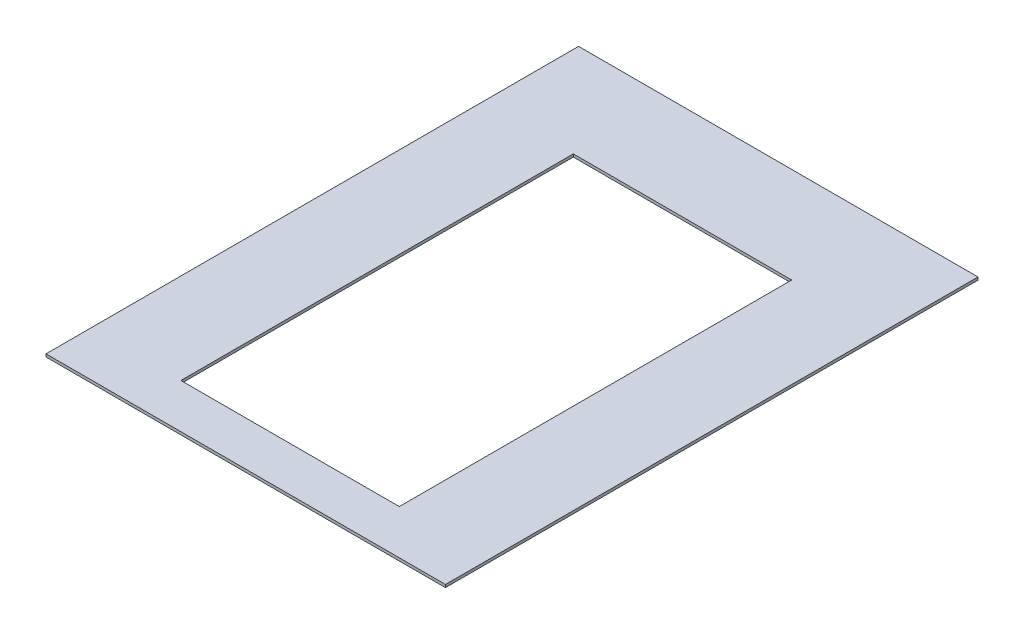
from build123d import *

# Parameters (mm, degrees)
SKETCH1_W           = 457.2
SKETCH1_H           = 609.6
SKETCH1_W_2         = 250
SKETCH1_H_2         = 449.2
BOSS_EXTRUDE1_DEPTH = 1.5875


with BuildPart() as part:
    # Sketch1 → Boss-Extrude1 (new body, symmetric)
    with BuildSketch(Plane(origin=(0, 0, 0), x_dir=(1, 0, 0), z_dir=(0, 1, 0))):
        Rectangle(SKETCH1_W, SKETCH1_H)
        with Locations((0, -29.4)):
            Rectangle(SKETCH1_W_2, SKETCH1_H_2, mode=Mode.SUBTRACT)
    extrude(amount=BOSS_EXTRUDE1_DEPTH, both=True)


solid = part.part
